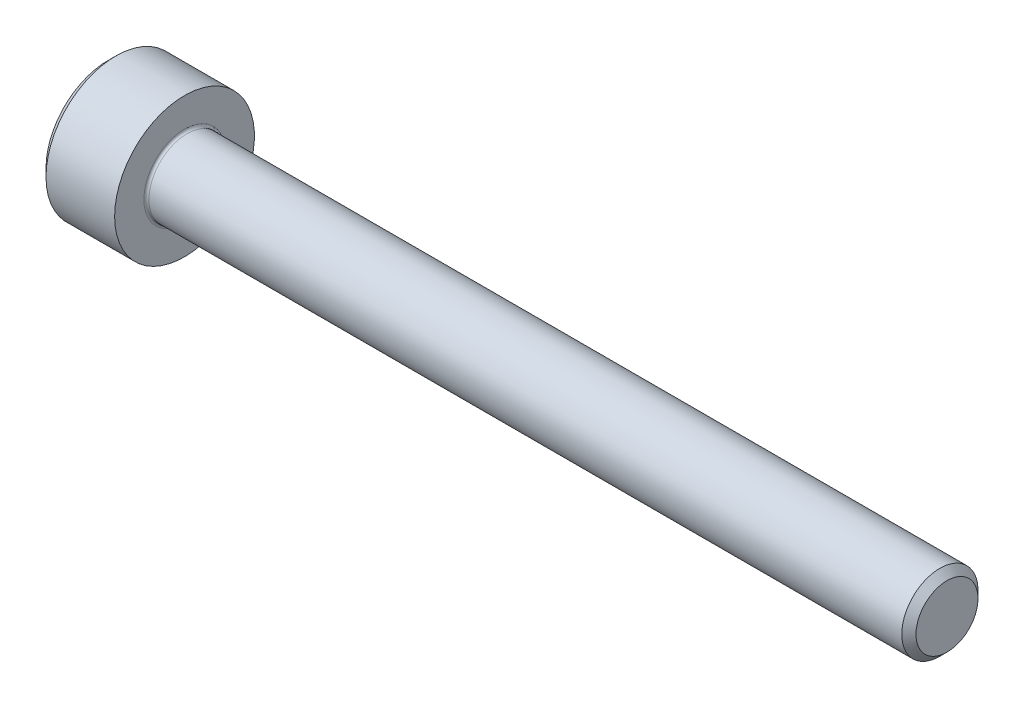
from build123d import *

# Parameters (mm, degrees)
FILLET1_R   = 0.1
HEX_2_DEPTH = 1.3


with BuildPart() as part:
    # BodySke → Base-Revolve (revolve)
    with BuildSketch(Plane.XY):
        Polygon((0, 0), (0, 2.45), (0.3, 2.75), (3, 2.75), (3, 1.5), (32.7195, 1.5), (33, 1.2195), (33, 0), align=None)
    revolve(axis=Axis((-31.75, 0, 0), (1, 0, 0)))

    # Fillet1
    fillet1_edges = [part.edges().sort_by_distance(p)[0] for p in [
        (3, -1.5, 0),
    ]]
    fillet(fillet1_edges, radius=FILLET1_R)

    # Sketch2 → Hex-PreBroach (revolve, cut)
    with BuildSketch(Plane.XY):
        Polygon((0, 1.28), (1.3, 1.28), (2.039008345, 0), (0, 0), align=None)
    revolve(axis=Axis((0, 0, 0), (1, 0, 0)), mode=Mode.SUBTRACT)

    # Sketch3 → Hex 2 (cut)
    with BuildSketch(Plane(origin=(0, 0, 0), x_dir=(0, 0.500000000000001, 0.866025403784438), z_dir=(-1, 0, 0))):
        Polygon((0.739008345, 1.28), (-0.739008345, 1.28), (-1.478016689, 0), (-0.739008345, -1.28), (0.739008345, -1.28), (1.478016689, 0), align=None)
    extrude(amount=-HEX_2_DEPTH, mode=Mode.SUBTRACT)


solid = part.part
